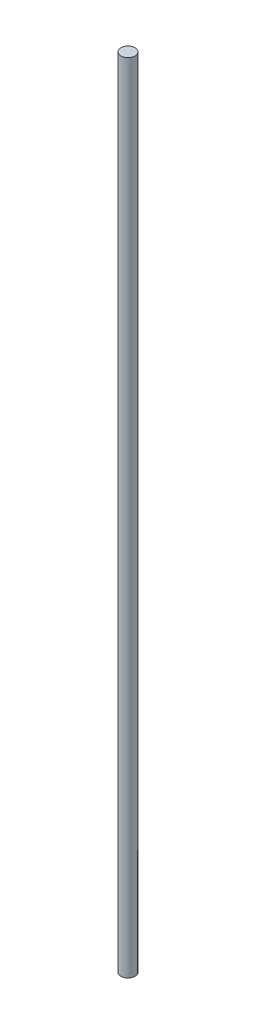
from build123d import *

# Parameters (mm, degrees)
SKETCH1_R           = 1.5875
BOSS_EXTRUDE1_DEPTH = 177.8


with BuildPart() as part:
    # Sketch1 → Boss-Extrude1 (new body)
    with BuildSketch(Plane(origin=(0, 0, 0), x_dir=(1, 0, 0), z_dir=(0, 1, 0))):
        Circle(SKETCH1_R)
    extrude(amount=BOSS_EXTRUDE1_DEPTH)


solid = part.part
